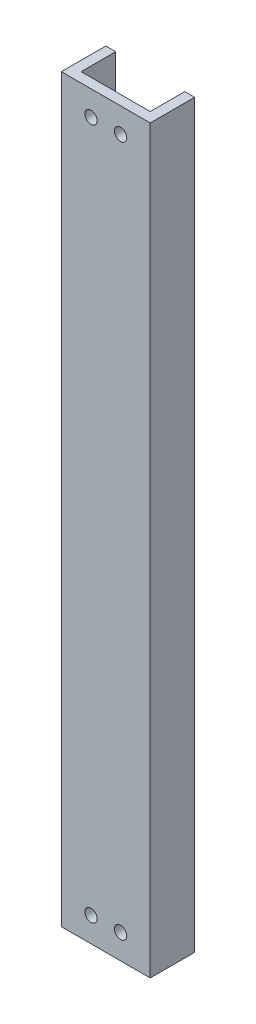
from build123d import *

# Parameters (mm, degrees)
BOSS_EXTRUDE1_DEPTH = 150
SKETCH2_R           = 1.25
CUT_EXTRUDE1_DEPTH  = 10


with BuildPart() as part:
    # Sketch1 → Boss-Extrude1 (new body)
    with BuildSketch(Plane(origin=(0, 0, 0), x_dir=(1, 0, 0), z_dir=(0, 1, 0))):
        Polygon((-7, 4.5), (-7, -2.5), (7, -2.5), (7, 4.5), (9, 4.5), (9, -4.5), (-9, -4.5), (-9, 4.5), align=None)
    extrude(amount=BOSS_EXTRUDE1_DEPTH)

    # Sketch2 → Cut-Extrude1 (cut)
    with BuildSketch(Plane(origin=(0, 0, 2.5), x_dir=(-1, 0, 0), z_dir=(0, 0, -1))):
        with Locations((-3, 5)):
            Circle(SKETCH2_R)
        with Locations((3, 5)):
            Circle(SKETCH2_R)
        with Locations((3, 145)):
            Circle(SKETCH2_R)
        with Locations((-3, 145)):
            Circle(SKETCH2_R)
    extrude(amount=-CUT_EXTRUDE1_DEPTH, mode=Mode.SUBTRACT)


solid = part.part
